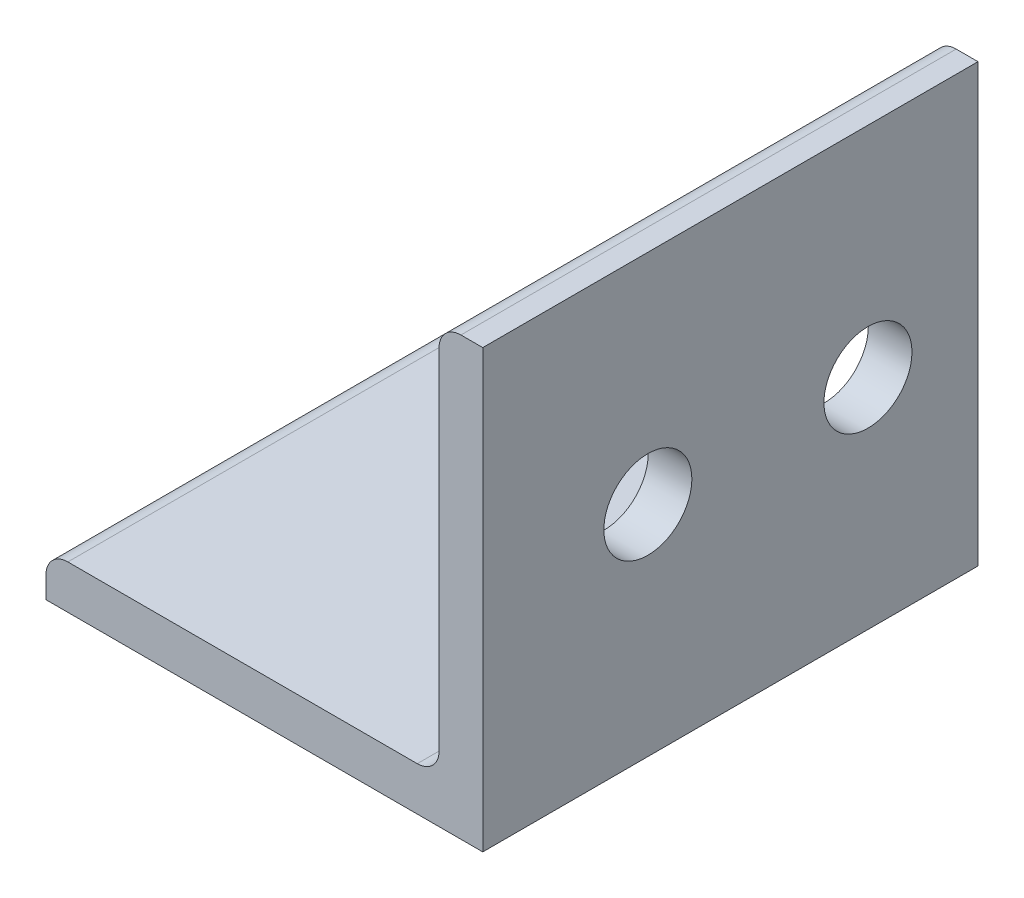
from build123d import *

# Parameters (mm, degrees)
BOSS_EXTRUDE1_DEPTH = 152.4
CUT_EXTRUDE1_REACH  = 17.875
SKETCH3_R           = 1.6
CUT_EXTRUDE2_DEPTH  = 286.8
CUT_EXTRUDE3_REACH  = 17.875
SKETCH5_R           = 1.5875


with BuildPart() as part:
    # Sketch2 → Boss-Extrude1 (new body, symmetric)
    with BuildSketch(Plane.XY):
        with BuildLine():
            Line((-7.9375, 0), (7.9375, 0))
            Line((7.9375, 0), (7.9375, 15.875))
            Line((7.9375, 15.875), (7.14375, 15.875))
            ThreePointArc((7.14375, 15.875), (6.582483992, 15.642516008), (6.35, 15.08125))
            Line((6.35, 15.08125), (6.35, 2.38125))
            ThreePointArc((6.35, 2.38125), (6.117516008, 1.819983992), (5.55625, 1.5875))
            Line((5.55625, 1.5875), (-7.14375, 1.5875))
            ThreePointArc((-7.14375, 1.5875), (-7.705016008, 1.355016008), (-7.9375, 0.79375))
            Line((-7.9375, 0.79375), (-7.9375, 0))
        make_face()
    extrude(amount=BOSS_EXTRUDE1_DEPTH, both=True)

    # Sketch3 → Cut-Extrude1 (cut, up to next)
    with BuildSketch(Plane(origin=(7.9375, 0, 0), x_dir=(0, 0, -1), z_dir=(1, 0, 0)), mode=Mode.PRIVATE) as cut_extrude1_sk1:
        with Locations((148.4, 7.9375)):
            Circle(SKETCH3_R)
    cut_extrude1_tool1 = extrude(cut_extrude1_sk1.sketch, amount=-CUT_EXTRUDE1_REACH, mode=Mode.PRIVATE) & part.part
    add(cut_extrude1_tool1.solids().sort_by_distance((7.9375, 7.9375, -148.4))[0], mode=Mode.SUBTRACT)
    # Sketch3 → Cut-Extrude1 (cut, up to next)
    with BuildSketch(Plane(origin=(7.9375, 0, 0), x_dir=(0, 0, -1), z_dir=(1, 0, 0)), mode=Mode.PRIVATE) as cut_extrude1_sk2:
        with Locations((140.4, 7.9375)):
            Circle(SKETCH3_R)
    cut_extrude1_tool2 = extrude(cut_extrude1_sk2.sketch, amount=-CUT_EXTRUDE1_REACH, mode=Mode.PRIVATE) & part.part
    add(cut_extrude1_tool2.solids().sort_by_distance((7.9375, 7.9375, -140.4))[0], mode=Mode.SUBTRACT)

    # Sketch4 → Cut-Extrude2 (cut)
    with BuildSketch(Plane.XY.offset(152.4)):
        with BuildLine():
            Line((-7.9375, 0.79375), (-7.9375, 0))
            Line((-7.9375, 0), (7.9375, 0))
            Line((7.9375, 0), (7.9375, 15.875))
            Line((7.9375, 15.875), (7.14375, 15.875))
            ThreePointArc((7.14375, 15.875), (6.582483992, 15.642516008), (6.35, 15.08125))
            Line((6.35, 15.08125), (6.35, 2.38125))
            ThreePointArc((6.35, 2.38125), (6.117516008, 1.819983992), (5.55625, 1.5875))
            Line((5.55625, 1.5875), (-7.14375, 1.5875))
            ThreePointArc((-7.14375, 1.5875), (-7.705016008, 1.355016008), (-7.9375, 0.79375))
        make_face()
    extrude(amount=-CUT_EXTRUDE2_DEPTH, mode=Mode.SUBTRACT)

    # Sketch5 → Cut-Extrude3 (cut, up to next)
    with BuildSketch(Plane.XZ, mode=Mode.PRIVATE) as cut_extrude3_sk1:
        with Locations((0, -143.4)):
            Circle(SKETCH5_R)
    cut_extrude3_tool1 = extrude(cut_extrude3_sk1.sketch, amount=-CUT_EXTRUDE3_REACH, mode=Mode.PRIVATE) & part.part
    add(cut_extrude3_tool1.solids().sort_by_distance((0, 0, -143.4))[0], mode=Mode.SUBTRACT)


solid = part.part
